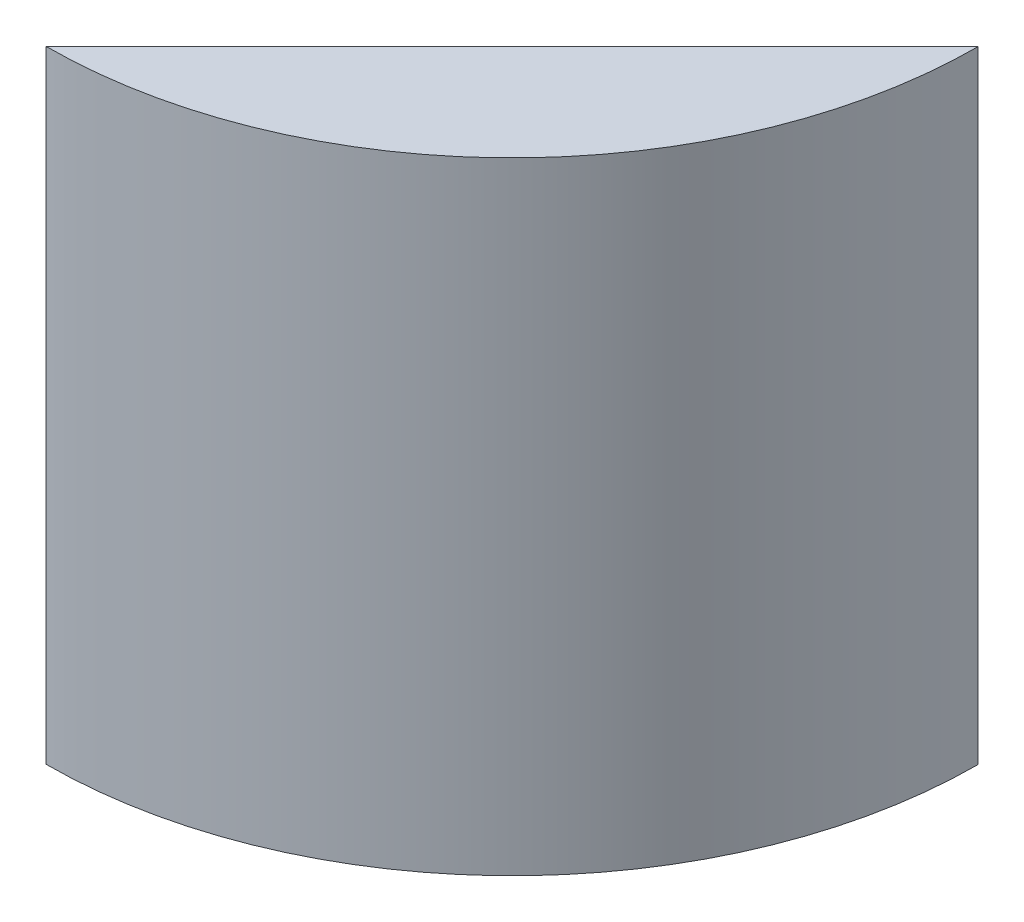
from build123d import *

# Parameters (mm, degrees)
SKETCH1_R           = 85.725
BOSS_EXTRUDE1_DEPTH = 114.3
CUT_EXTRUDE1_DEPTH  = 152.4
SKETCH3_R           = 2.778125
CUT_EXTRUDE2_DEPTH  = 12.7
SKETCH4_R           = 6.985
CUT_EXTRUDE3_DEPTH  = 6.096


with BuildPart() as part:
    # Sketch1 → Boss-Extrude1 (new body)
    with BuildSketch(Plane(origin=(0, 0, 0), x_dir=(1, 0, 0), z_dir=(0, 1, 0))):
        Circle(SKETCH1_R)
    extrude(amount=BOSS_EXTRUDE1_DEPTH)

    # Sketch2 → Cut-Extrude1 (cut)
    with BuildSketch(Plane(origin=(0, 114.3, 0), x_dir=(1, 0, 0), z_dir=(0, 1, 0))):
        Polygon((85.724933621, -0.10668), (0, -85.725), (-45.627504124, -96.719379999), (-137.428949547, 46.173941299), (19.12530113, 101.910533163), (109.833872203, 30.600481808), align=None)
    extrude(amount=-CUT_EXTRUDE1_DEPTH, mode=Mode.SUBTRACT)

    # Sketch3 → Cut-Extrude2 (cut)
    with BuildSketch(Plane(origin=(42.862466811, 0, 42.91584), x_dir=(-0.707546622, 0, 0.706666667), z_dir=(-0.706666667, 0, -0.707546622))):
        with Locations((-37.719, 87.122)):
            Circle(SKETCH3_R)
        with Locations((-14.859, 87.122)):
            Circle(SKETCH3_R)
        with Locations((-37.719, 29.21)):
            Circle(SKETCH3_R)
        with Locations((-14.859, 29.21)):
            Circle(SKETCH3_R)
    extrude(amount=-CUT_EXTRUDE2_DEPTH, mode=Mode.SUBTRACT)

    # Sketch4 → Cut-Extrude3 (cut)
    with BuildSketch(Plane(origin=(0, 0, 0), x_dir=(-1, 0, 0), z_dir=(0, -1, 0))):
        with Locations((-51.720733405, -51.785137083)):
            Circle(SKETCH4_R)
    extrude(amount=-CUT_EXTRUDE3_DEPTH, mode=Mode.SUBTRACT)


solid = part.part
